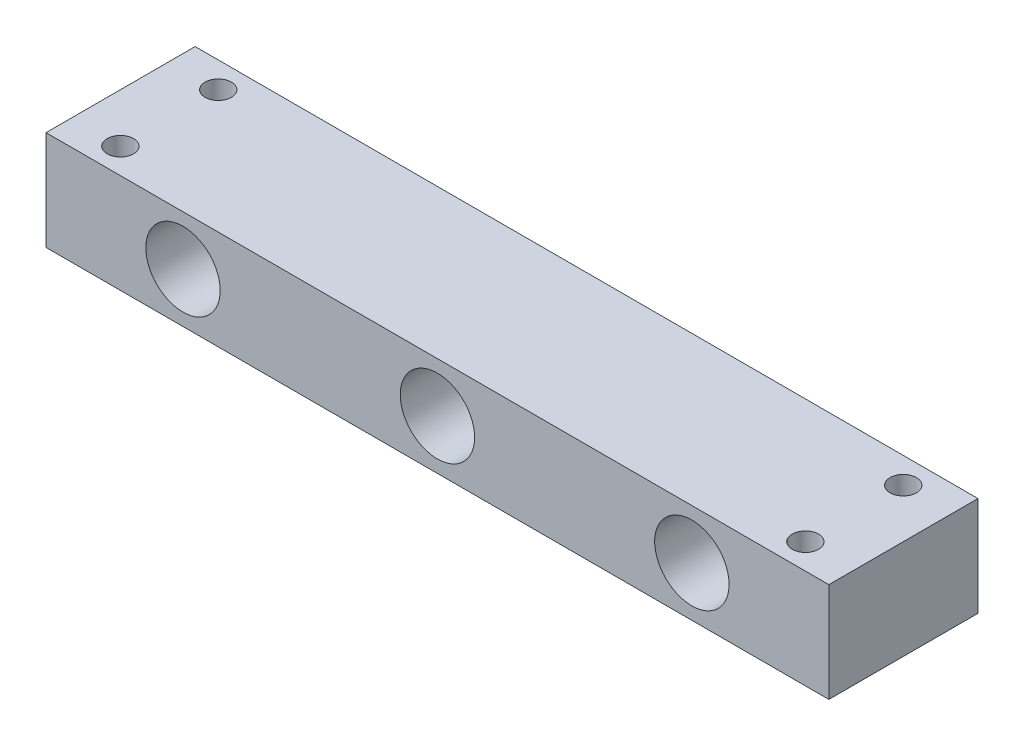
from build123d import *

# Parameters (mm, degrees)
SKETCH1_W           = 400
SKETCH1_H           = 76.2
BOSS_EXTRUDE1_DEPTH = 50.8
SKETCH3_R           = 6.75
CUT_EXTRUDE2_DEPTH  = 50.8
SKETCH5_R           = 19
CUT_EXTRUDE3_DEPTH  = 77.2


with BuildPart() as part:
    # Sketch1 → Boss-Extrude1 (new body)
    with BuildSketch(Plane(origin=(0, 0, 0), x_dir=(1, 0, 0), z_dir=(0, 1, 0))):
        with Locations((200, 38.1)):
            Rectangle(SKETCH1_W, SKETCH1_H)
    extrude(amount=BOSS_EXTRUDE1_DEPTH)

    # Sketch3 → Cut-Extrude2 (cut)
    with BuildSketch(Plane(origin=(0, 50.8, 0), x_dir=(1, 0, 0), z_dir=(0, 1, 0))):
        with Locations((25, 63)):
            Circle(SKETCH3_R)
        with Locations((25, 13)):
            Circle(SKETCH3_R)
        with Locations((375, 63)):
            Circle(SKETCH3_R)
        with Locations((375, 13)):
            Circle(SKETCH3_R)
    extrude(amount=-CUT_EXTRUDE2_DEPTH, mode=Mode.SUBTRACT)

    # Sketch5 → Cut-Extrude3 (cut, through all)
    with BuildSketch(Plane.XY):
        with Locations((200, 25.4)):
            Circle(SKETCH5_R)
        with Locations((70, 25.4)):
            Circle(SKETCH5_R)
        with Locations((330, 25.4)):
            Circle(SKETCH5_R)
    extrude(amount=-CUT_EXTRUDE3_DEPTH, mode=Mode.SUBTRACT)


solid = part.part
